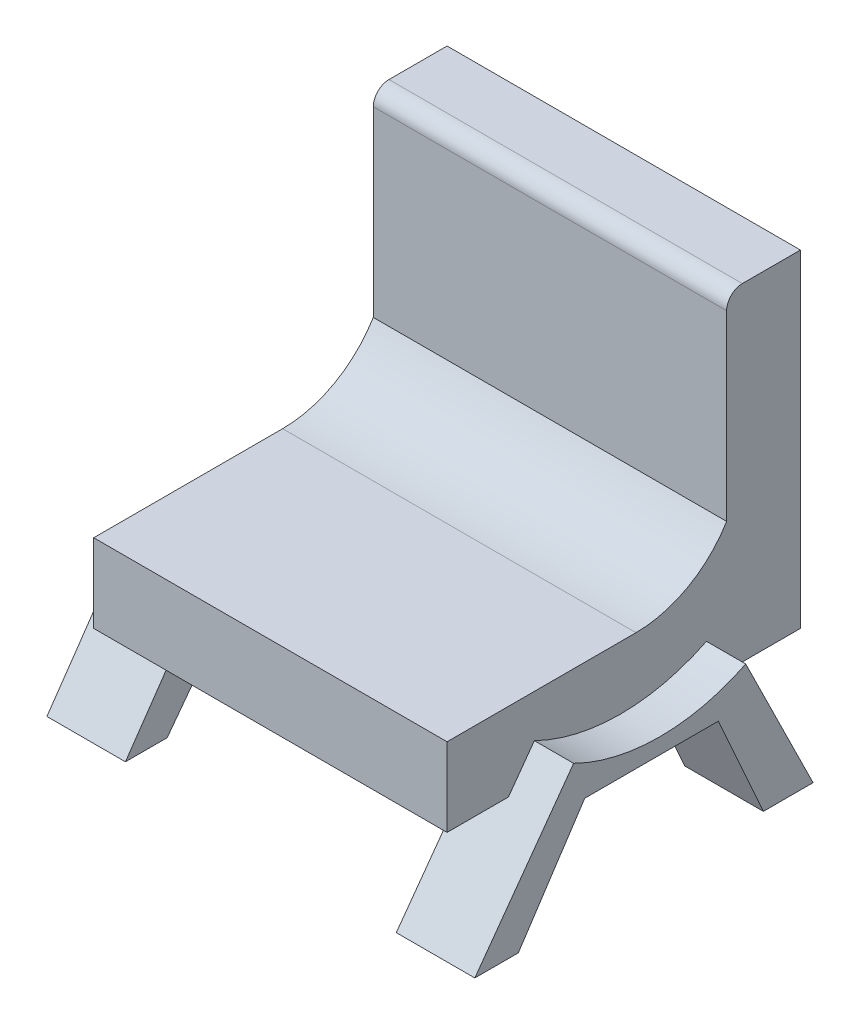
from build123d import *

# Parameters (mm, degrees)
BOSS_EXTRUDE2_DEPTH = 90
BOSS_EXTRUDE4_DEPTH = 10
BOSS_EXTRUDE5_DEPTH = 10
FILLET1_R           = 10


with BuildPart() as part:
    # Sketch1 → Boss-Extrude2 (new body)
    with BuildSketch(Plane(origin=(0, 0, 0), x_dir=(0, 0, -1), z_dir=(1, 0, 0))):
        with BuildLine():
            Line((-48.118811881, 0), (41.881188119, 0))
            Line((41.881188119, 0), (41.881188119, 83.466961913))
            Line((41.881188119, 83.466961913), (27.086166787, 83.466961913))
            ThreePointArc((27.086166787, 83.466961913), (24.257739663, 82.295389038), (23.086166787, 79.466961913))
            Line((23.086166787, 79.466961913), (23.086166787, 32.998967786))
            ThreePointArc((23.086166787, 32.998967786), (13.24711535, 23.473123138), (0, 20))
            Line((0, 20), (-48.118811881, 20))
            Line((-48.118811881, 20), (-48.118811881, 0))
        make_face()
    extrude(amount=-BOSS_EXTRUDE2_DEPTH)

    # Sketch2 → Boss-Extrude4 (add, symmetric)
    with BuildSketch(Plane(origin=(0, 0, 0), x_dir=(0, 0, -1), z_dir=(1, 0, 0))):
        with BuildLine():
            Line((-32.487137017, 0), (-51.053894903, -25.643291777))
            Line((-51.053894903, -25.643291777), (-39.969263329, -25.643291777))
            Line((-39.969263329, -25.643291777), (-23.065200179, 0))
            Line((-23.065200179, 0), (10.956889222, 0))
            Line((10.956889222, 0), (22.448464713, -25.643291777))
            Line((22.448464713, -25.643291777), (35.102344658, -25.643291777))
            Line((35.102344658, -25.643291777), (22.448464713, 0))
            Line((22.448464713, 0), (17.947936645, 9.120392711))
            ThreePointArc((17.947936645, 9.120392711), (-3.967837589, 4.007448958), (-25.883611823, 9.120392711))
            Line((-25.883611823, 9.120392711), (-32.487137017, 0))
        make_face()
    extrude(amount=BOSS_EXTRUDE4_DEPTH, both=True)

    # Sketch5 → Boss-Extrude5 (add, symmetric)
    with BuildSketch(Plane.ZY.offset(90)):
        Polygon((-15.060305743, 7.399353966), (28.775027298, 7.399353966), (50.037353524, -23.467201706), (39.406190411, -23.467201706), (21.793994687, 0), (-13.237941151, 0), (-23.164531139, -23.467201706), (-36.584121335, -23.467201706), (-21.202482156, 7.399353966), align=None)
    extrude(amount=BOSS_EXTRUDE5_DEPTH, both=True)

    # Fillet1
    fillet1_edges = [part.edges().sort_by_distance(p)[0] for p in [
        (-95, 7.399353966, 28.775027298),
        (-95, 7.399353966, -21.202482156),
    ]]
    fillet(fillet1_edges, radius=FILLET1_R)


solid = part.part
